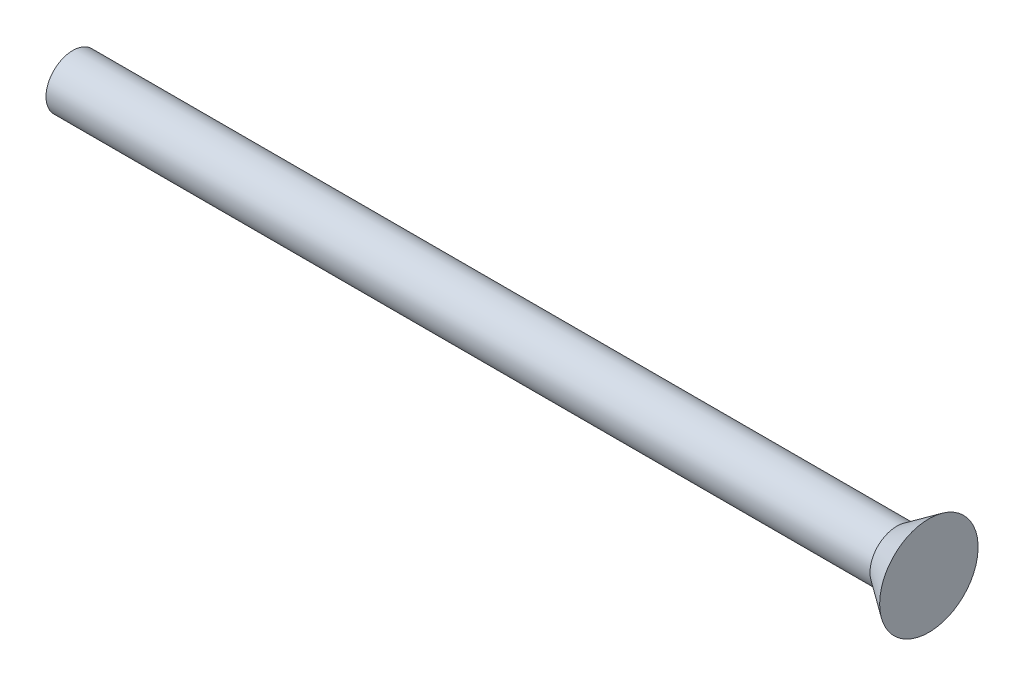
from build123d import *


with BuildPart() as part:
    # 草图1 → 旋转1 (revolve)
    with BuildSketch(Plane.XY):
        Polygon((-30, 0), (-30, 1.25), (8.5, 1.25), (10, 2.3), (10, 0), align=None)
    revolve(axis=Axis((-53.844089168, 0, 0), (1, 0, 0)))


solid = part.part
